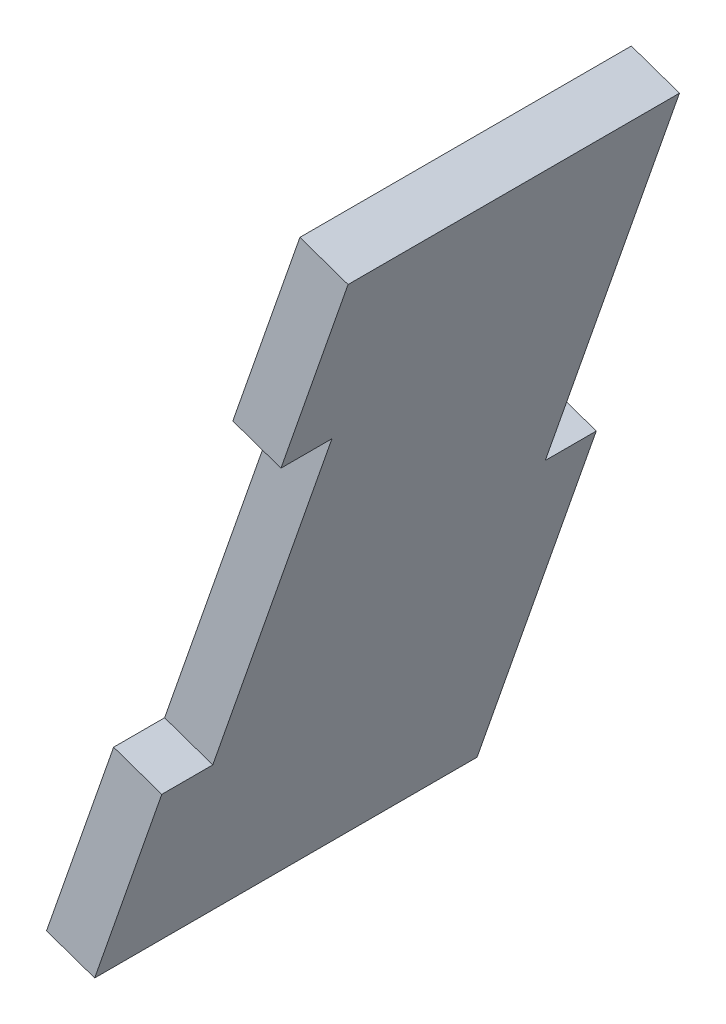
from build123d import *

# Parameters (mm, degrees)
BOSS_EXTRUDE1_DEPTH = 23.8125
SKETCH2_W           = 3.175
SKETCH2_H           = 25.4
SKETCH2_H_2         = 22.557316078
CUT_EXTRUDE1_DEPTH  = 3.175


with BuildPart() as part:
    # Sketch1 → Boss-Extrude1 (new body)
    with BuildSketch(Plane.XY):
        Polygon((322.665849031, 315.38832698), (306.887039832, 270.101095383), (309.885267674, 269.056463963), (325.664076873, 314.34369556), align=None)
    extrude(amount=-BOSS_EXTRUDE1_DEPTH)

    # Sketch2 → Cut-Extrude1 (cut)
    with BuildSketch(Plane(origin=(192.743701136, -67.155045192, 0), x_dir=(0, 0, -1), z_dir=(0.94432373, -0.32901777, 0))):
        with Locations((22.225, 391.291479466)):
            Rectangle(SKETCH2_W, SKETCH2_H)
        with Locations((1.5875, 380.012821427)):
            Rectangle(SKETCH2_W, SKETCH2_H_2)
    extrude(amount=-CUT_EXTRUDE1_DEPTH, mode=Mode.SUBTRACT)


solid = part.part
